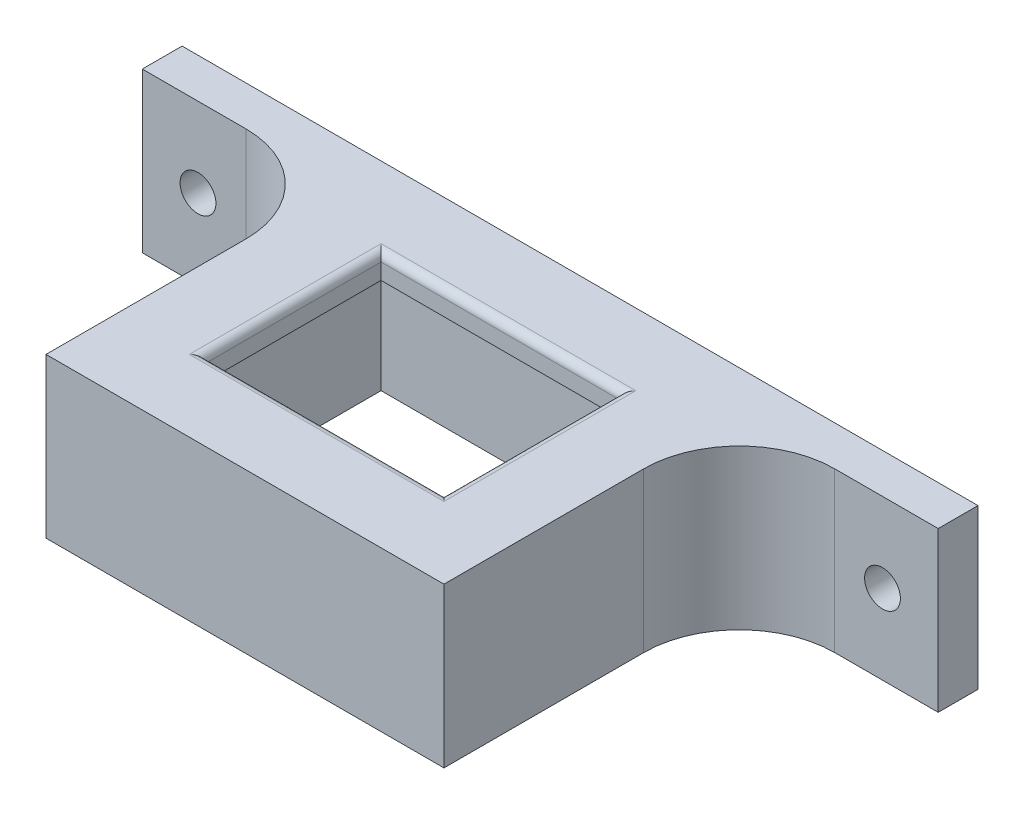
from build123d import *

# Parameters (mm, degrees)
SKETCH1_W                      = 50
SKETCH1_H                      = 42.1
SKETCH1_W_2                    = 30
SKETCH1_H_2                    = 22.1
BOSS_EXTRUDE2_DEPTH            = 3
FILLET1_R                      = 1
SKETCH2_W                      = 50
SKETCH2_H                      = 42.1
SKETCH2_W_2                    = 40
SKETCH2_H_2                    = 32.1
BOSS_EXTRUDE3_DEPTH            = 17
SKETCH3_W                      = 25
SKETCH3_H                      = 20
BOSS_EXTRUDE4_DEPTH            = 5
M4_CLEARANCE_HOLE1_D           = 4.5
M4_CLEARANCE_HOLE1_CSINK_D     = 4.55
M4_CLEARANCE_HOLE1_CSINK_ANGLE = 90
FILLET2_R                      = 12


with BuildPart() as part:
    # Sketch1 → Boss-Extrude2 (new body)
    with BuildSketch(Plane(origin=(0, 0, 0), x_dir=(1, 0, 0), z_dir=(0, 1, 0))):
        Rectangle(SKETCH1_W, SKETCH1_H)
        Rectangle(SKETCH1_W_2, SKETCH1_H_2, mode=Mode.SUBTRACT)
    extrude(amount=-BOSS_EXTRUDE2_DEPTH)

    # Fillet1
    fillet1_edges = [part.edges().sort_by_distance(p)[0] for p in [
        (15, 0, 0),
        (0, 0, -11.05),
        (-15, 0, 0),
        (0, 0, 11.05),
    ]]
    fillet(fillet1_edges, radius=FILLET1_R)

    # Sketch2 → Boss-Extrude3 (add)
    with BuildSketch(Plane.XZ.offset(3)):
        Rectangle(SKETCH2_W, SKETCH2_H)
        Rectangle(SKETCH2_W_2, SKETCH2_H_2, mode=Mode.SUBTRACT)
    extrude(amount=BOSS_EXTRUDE3_DEPTH)

    # Sketch3 → Boss-Extrude4 (add)
    with BuildSketch(Plane(origin=(0, 0, -21.05), x_dir=(-1, 0, 0), z_dir=(0, 0, -1))):
        with Locations((-37.5, -10)):
            Rectangle(SKETCH3_W, SKETCH3_H)
    boss_extrude4 = extrude(amount=-BOSS_EXTRUDE4_DEPTH)

    # M4 Clearance Hole1 (through all)
    with Locations(Plane(origin=(43, -10, -21.05), x_dir=(-1, 0, 0), z_dir=(0, 0, -1))):
        with Locations((0, 0)):
            m4_clearance_hole1 = CounterSinkHole(M4_CLEARANCE_HOLE1_D / 2, M4_CLEARANCE_HOLE1_CSINK_D / 2, counter_sink_angle=M4_CLEARANCE_HOLE1_CSINK_ANGLE)

    # Mirror4: Boss-Extrude4, M4 Clearance Hole1 across plane
    add(boss_extrude4.mirror(Plane(origin=(0, 0, 0), x_dir=(0, 0, 1), z_dir=(1, 0, 0))))
    add(m4_clearance_hole1.mirror(Plane(origin=(0, 0, 0), x_dir=(0, 0, 1), z_dir=(1, 0, 0))), mode=Mode.SUBTRACT)

    # Fillet2
    fillet2_edges = [part.edges().sort_by_distance(p)[0] for p in [
        (25, -10, -16.05),
        (-25, -10, -16.05),
    ]]
    fillet(fillet2_edges, radius=FILLET2_R)


solid = part.part
